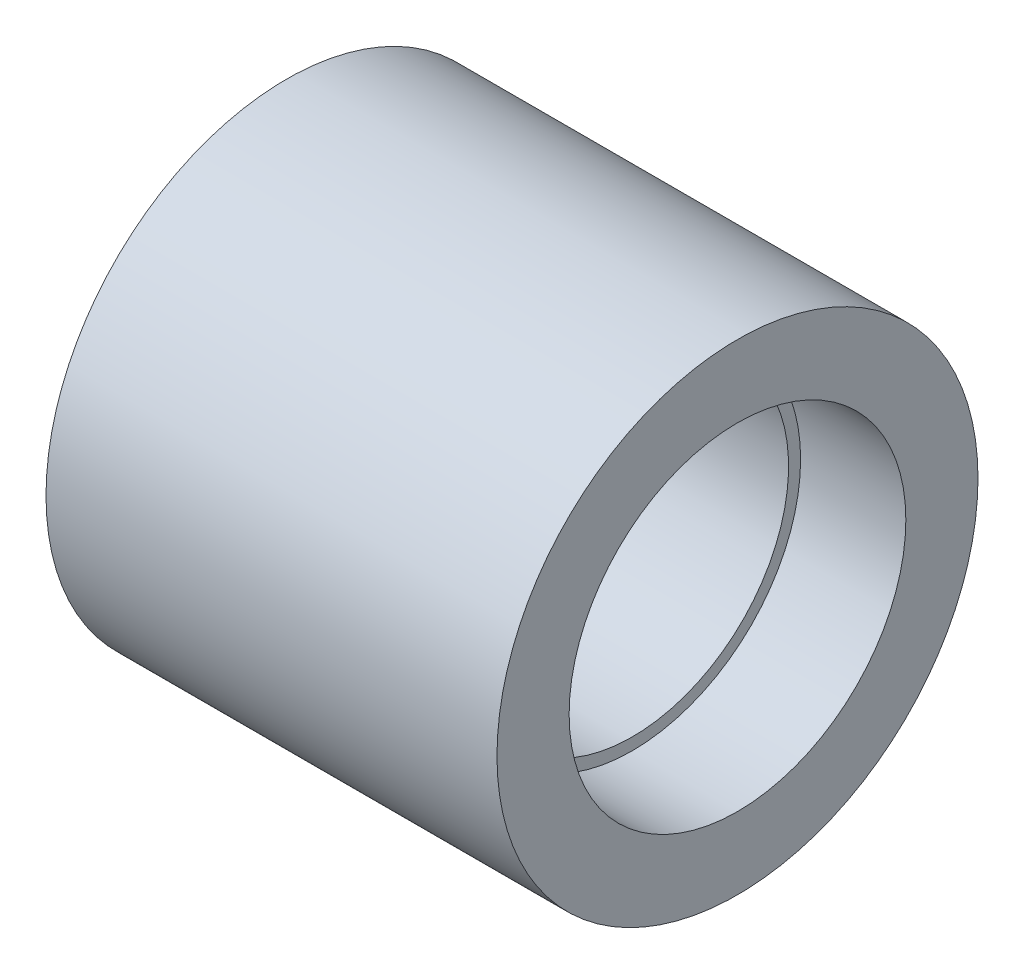
from build123d import *

# Parameters (mm, degrees)
SKETCH1_W   = 75
SKETCH1_H   = 12
SKETCH1_W_2 = 40
SKETCH1_H_2 = 2


with BuildPart() as part:
    # Sketch1 → Revolve1 (revolve)
    with BuildSketch(Plane.XY):
        with Locations((0, 64)):
            Rectangle(SKETCH1_W, SKETCH1_H)
        with Locations((0, 57)):
            Rectangle(SKETCH1_W_2, SKETCH1_H_2)
    revolve(axis=Axis((-1000, 30, 0), (1, 0, 0)))


solid = part.part
